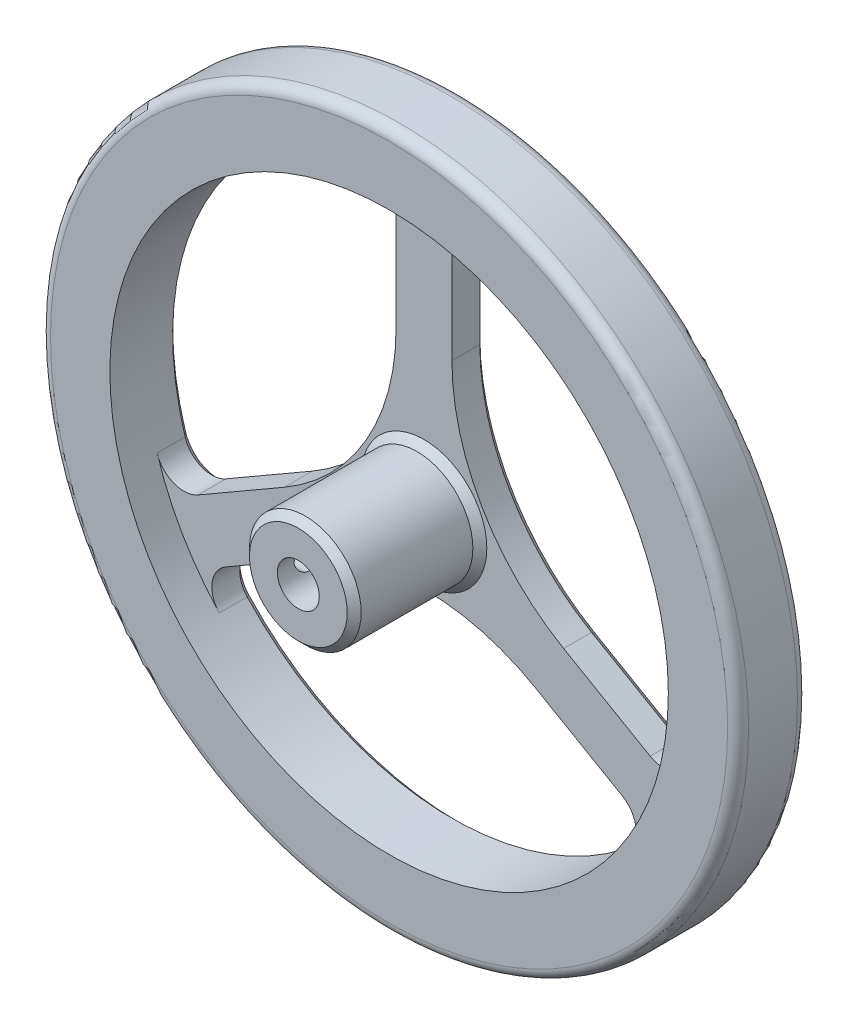
from build123d import *

# Parameters (mm, degrees)
SKETCH1_R           = 50
SKETCH1_R_2         = 40
BOSS_EXTRUDE1_DEPTH = 10
BOSS_EXTRUDE3_DEPTH = 5
FILLET1_R           = 32
FILLET2_R           = 4
CHAMFER1_SIZE       = 1
FILLET3_R           = 1.5
SKETCH2_R           = 8
SKETCH2_R_2         = 3
BOSS_EXTRUDE4_DEPTH = 18
CHAMFER2_SIZE       = 1
SKETCH3_R           = 1.6
CUT_EXTRUDE1_DEPTH  = 10


with BuildPart() as part:
    # Sketch1 → Boss-Extrude1 (new body)
    with BuildSketch(Plane.XY):
        Circle(SKETCH1_R)
        Circle(SKETCH1_R_2, mode=Mode.SUBTRACT)
    extrude(amount=BOSS_EXTRUDE1_DEPTH)

    # Sketch1_5 → Boss-Extrude3 (add)
    with BuildSketch(Plane.XY):
        with BuildLine():
            ThreePointArc((4, 39.799497484), (0, 40), (-4, 39.799497484))
            Line((-4, 39.799497484), (-4, 2.309401077))
            Line((-4, 2.309401077), (-36.467375879, -16.435647127))
            ThreePointArc((-36.467375879, -16.435647127), (-34.641016151, -20), (-32.467375879, -23.363850357))
            Line((-32.467375879, -23.363850357), (0, -4.618802154))
            Line((0, -4.618802154), (32.467375879, -23.363850357))
            ThreePointArc((32.467375879, -23.363850357), (34.641016151, -20), (36.467375879, -16.435647127))
            Line((36.467375879, -16.435647127), (4, 2.309401077))
            Line((4, 2.309401077), (4, 39.799497484))
        make_face()
    extrude(amount=BOSS_EXTRUDE3_DEPTH)

    # Fillet1
    fillet1_edges = [part.edges().sort_by_distance(p)[0] for p in [
        (-4, 2.309401077, 2.5),
        (0, -4.618802154, 2.5),
        (4, 2.309401077, 2.5),
    ]]
    fillet(fillet1_edges, radius=FILLET1_R)

    # Fillet2
    fillet2_edges = [part.edges().sort_by_distance(p)[0] for p in [
        (-36.467375879, -16.435647127, 2.5),
        (-32.467375879, -23.363850357, 2.5),
        (32.467375879, -23.363850357, 2.5),
        (36.467375879, -16.435647127, 2.5),
        (4, 39.799497484, 2.5),
        (-4, 39.799497484, 2.5),
    ]]
    fillet(fillet2_edges, radius=FILLET2_R)

    # Chamfer1
    chamfer1_edges = [part.edges().sort_by_distance(p)[0] for p in [
        (0, -9.569219382, 0),
        (-8.287187079, 4.784609691, 0),
        (8.287187079, 4.784609691, 0),
        (26.198684154, -10.507015195, 0),
        (31.269438399, 24.944382578, 0),
        (0, -40, 0),
        (-34.641016151, 20, 0),
        (22.198684154, -17.435218425, 0),
        (-26.198684154, -10.507015195, 0),
        (-22.198684154, -17.435218425, 0),
        (-4, 27.94223362, 0),
        (4, 27.94223362, 0),
        (35.85816198, -14.345444364, 0),
        (30.352600238, -23.881357026, 0),
        (-35.85816198, -14.345444364, 0),
        (-30.352600238, -23.881357026, 0),
        (-5.505561742, 38.226801389, 0),
        (5.505561742, 38.226801389, 0),
    ]]
    chamfer(chamfer1_edges, length=CHAMFER1_SIZE)

    # Fillet3
    fillet3_edges = [part.edges().sort_by_distance(p)[0] for p in [
        (-50, 0, 10),
        (-50, 0, 0),
    ]]
    fillet(fillet3_edges, radius=FILLET3_R)

    # Sketch2 → Boss-Extrude4 (add)
    with BuildSketch(Plane.XY.offset(5)):
        Circle(SKETCH2_R)
        Circle(SKETCH2_R_2, mode=Mode.SUBTRACT)
    extrude(amount=BOSS_EXTRUDE4_DEPTH)

    # Chamfer2
    chamfer2_edges = [part.edges().sort_by_distance(p)[0] for p in [
        (-8, 0, 23),
        (-8, 0, 5),
    ]]
    chamfer(chamfer2_edges, length=CHAMFER2_SIZE)

    # Sketch3 → Cut-Extrude1 (cut)
    with BuildSketch(Plane(origin=(0, 0, 0), x_dir=(0, 0, -1), z_dir=(1, 0, 0))):
        with Locations((-19, 0)):
            Circle(SKETCH3_R)
        with Locations((-13, 0)):
            Circle(SKETCH3_R)
    extrude(amount=-CUT_EXTRUDE1_DEPTH, mode=Mode.SUBTRACT)


solid = part.part
